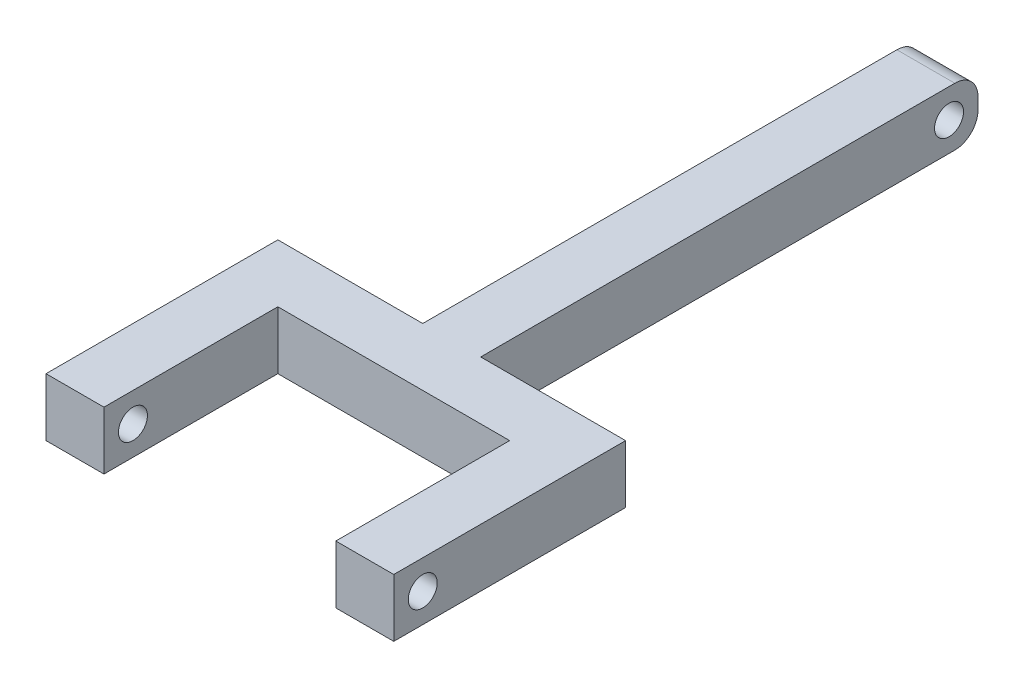
from build123d import *

# Parameters (mm, degrees)
SKETCH1_W                = 12.7
SKETCH1_H                = 12.7
BOSS_EXTRUDE1_DEPTH      = 41.656
BOSS_EXTRUDE1_DEPTH_BACK = 80.01
SKETCH4_W                = 12.7
SKETCH4_H                = 12.7
BOSS_EXTRUDE2_DEPTH      = 38.1
SKETCH5_W                = 12.7
SKETCH5_H                = 12.7
BOSS_EXTRUDE3_DEPTH      = 50.8
SKETCH6_R                = 3.175
CUT_EXTRUDE1_DEPTH       = 16.51
SKETCH7_R                = 3.175
CUT_EXTRUDE2_DEPTH       = 45.45
FILLET1_R                = 5.08


with BuildPart() as part:
    # Sketch1 → Boss-Extrude1 (new body, two sides)
    with BuildSketch(Plane.XY) as boss_extrude1_sk:
        Rectangle(SKETCH1_W, SKETCH1_H)
    extrude(amount=BOSS_EXTRUDE1_DEPTH)
    extrude(boss_extrude1_sk.sketch, amount=-BOSS_EXTRUDE1_DEPTH_BACK)

    # Sketch4 → Boss-Extrude2 (add, symmetric)
    with BuildSketch(Plane(origin=(0, 0, 0), x_dir=(0, 0, -1), z_dir=(1, 0, 0))):
        with Locations((-35.306, 0)):
            Rectangle(SKETCH4_W, SKETCH4_H)
    extrude(amount=BOSS_EXTRUDE2_DEPTH, both=True)

    # Sketch5 → Boss-Extrude3 (add)
    with BuildSketch(Plane(origin=(0, 0, 28.956), x_dir=(-1, 0, 0), z_dir=(0, 0, -1))):
        with Locations((-31.75, 0)):
            Rectangle(SKETCH5_W, SKETCH5_H)
    boss_extrude3 = extrude(amount=-BOSS_EXTRUDE3_DEPTH)

    # Sketch6 → Cut-Extrude1 (cut)
    with BuildSketch(Plane.ZY.offset(-25.4)):
        with Locations((73.406, 0)):
            Circle(SKETCH6_R)
    cut_extrude1 = extrude(amount=-CUT_EXTRUDE1_DEPTH, mode=Mode.SUBTRACT)

    # Mirror1: Boss-Extrude3, Cut-Extrude1 across plane
    add(boss_extrude3.mirror(Plane(origin=(0, 0, 0), x_dir=(0, 0, 1), z_dir=(1, 0, 0))))
    add(cut_extrude1.mirror(Plane(origin=(0, 0, 0), x_dir=(0, 0, 1), z_dir=(1, 0, 0))), mode=Mode.SUBTRACT)

    # Sketch7 → Cut-Extrude2 (cut, through all)
    with BuildSketch(Plane.ZY.offset(6.35)):
        with Locations((-73.66, 0)):
            Circle(SKETCH7_R)
    extrude(amount=-CUT_EXTRUDE2_DEPTH, mode=Mode.SUBTRACT)

    # Fillet1
    fillet1_edges = [part.edges().sort_by_distance(p)[0] for p in [
        (0, 6.35, -80.01),
        (0, -6.35, -80.01),
    ]]
    fillet(fillet1_edges, radius=FILLET1_R)


solid = part.part
